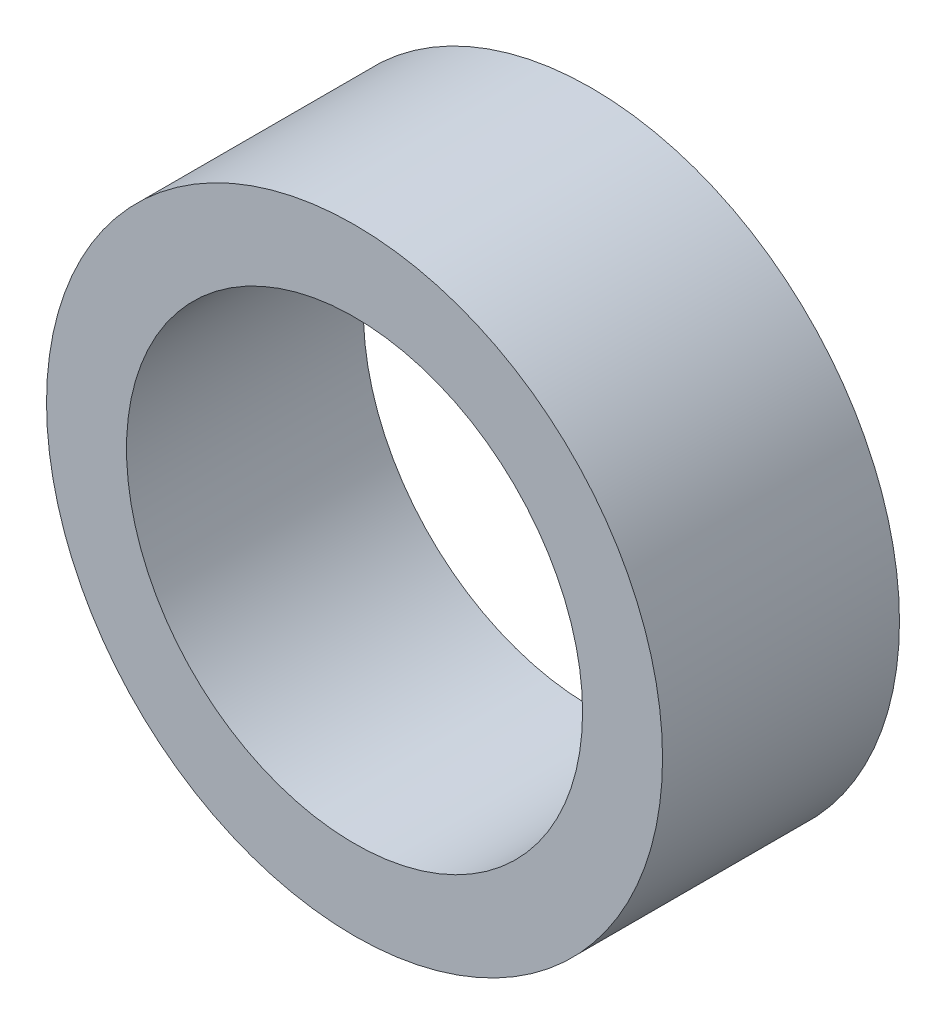
from build123d import *

# Parameters (mm, degrees)
SKETCH1_R           = 6.5
BOSS_EXTRUDE1_DEPTH = 5
SKETCH2_R           = 4.8125
CUT_EXTRUDE1_DEPTH  = 5


with BuildPart() as part:
    # Sketch1 → Boss-Extrude1 (new body)
    with BuildSketch(Plane.XY):
        Circle(SKETCH1_R)
    extrude(amount=BOSS_EXTRUDE1_DEPTH)

    # Sketch2 → Cut-Extrude1 (cut)
    with BuildSketch(Plane.XY.offset(5)):
        Circle(SKETCH2_R)
    extrude(amount=-CUT_EXTRUDE1_DEPTH, mode=Mode.SUBTRACT)


solid = part.part
